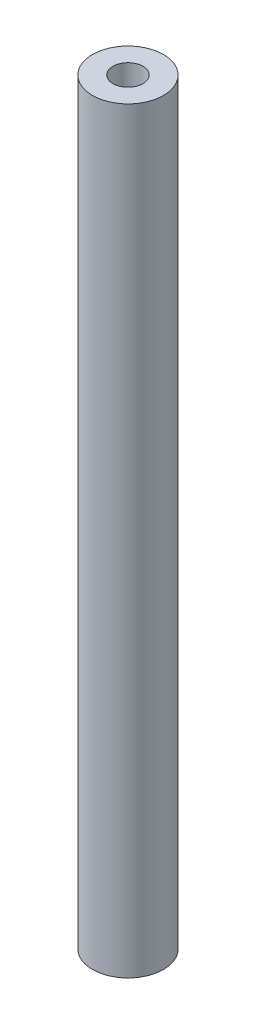
from build123d import *

# Parameters (mm, degrees)
SKETCH1_R                            = 4.7625
BOSS_EXTRUDE1_DEPTH                  = 50.8
F_10_32_TAPPED_HOLE1_D               = 4.0386
F_10_32_TAPPED_HOLE1_DEPTH           = 11.938
F_10_32_TAPPED_HOLE1_TIP             = 1.213317848
F_10_32_TAPPED_HOLE1_ON_FACE_2_D     = 4.0386
F_10_32_TAPPED_HOLE1_ON_FACE_2_DEPTH = 11.938
F_10_32_TAPPED_HOLE1_ON_FACE_2_TIP   = 1.213317848


with BuildPart() as part:
    # Sketch1 → Boss-Extrude1 (new body, symmetric)
    with BuildSketch(Plane(origin=(0, 0, 0), x_dir=(1, 0, 0), z_dir=(0, 1, 0))):
        Circle(SKETCH1_R)
    extrude(amount=BOSS_EXTRUDE1_DEPTH, both=True)

    # #10-32 Tapped Hole1
    with Locations(Plane.ZX.offset(50.8)):
        with Locations((0, 0)):
            Hole(F_10_32_TAPPED_HOLE1_D / 2, depth=F_10_32_TAPPED_HOLE1_DEPTH)
            with Locations((0, 0, -(F_10_32_TAPPED_HOLE1_DEPTH + F_10_32_TAPPED_HOLE1_TIP / 2))):  # 118° drill point
                Cone(0, F_10_32_TAPPED_HOLE1_D / 2, F_10_32_TAPPED_HOLE1_TIP, mode=Mode.SUBTRACT)

    # #10-32 Tapped Hole1 on face 2
    with Locations(Plane(origin=(0, -50.8, 0), x_dir=(0, 0, -1), z_dir=(0, -1, 0))):
        with Locations((0, 0)):
            Hole(F_10_32_TAPPED_HOLE1_ON_FACE_2_D / 2, depth=F_10_32_TAPPED_HOLE1_ON_FACE_2_DEPTH)
            with Locations((0, 0, -(F_10_32_TAPPED_HOLE1_ON_FACE_2_DEPTH + F_10_32_TAPPED_HOLE1_ON_FACE_2_TIP / 2))):  # 118° drill point
                Cone(0, F_10_32_TAPPED_HOLE1_ON_FACE_2_D / 2, F_10_32_TAPPED_HOLE1_ON_FACE_2_TIP, mode=Mode.SUBTRACT)


solid = part.part
